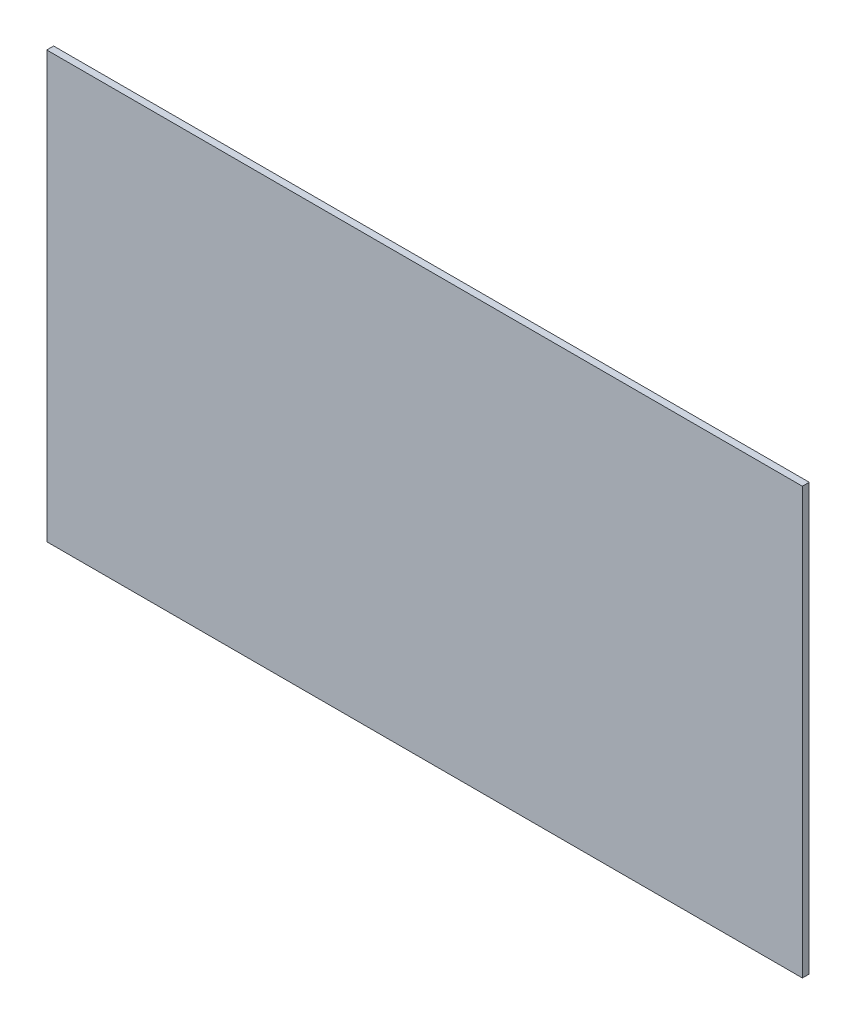
from build123d import *

# Parameters (mm, degrees)
SKETCH1_W           = 13.97
SKETCH1_H           = 7.874
BOSS_EXTRUDE1_DEPTH = 0.127


with BuildPart() as part:
    # Sketch1 → Boss-Extrude1 (new body)
    with BuildSketch(Plane.XY):
        with Locations((71.819809079, 263.320312433)):
            Rectangle(SKETCH1_W, SKETCH1_H)
    extrude(amount=BOSS_EXTRUDE1_DEPTH)


solid = part.part
